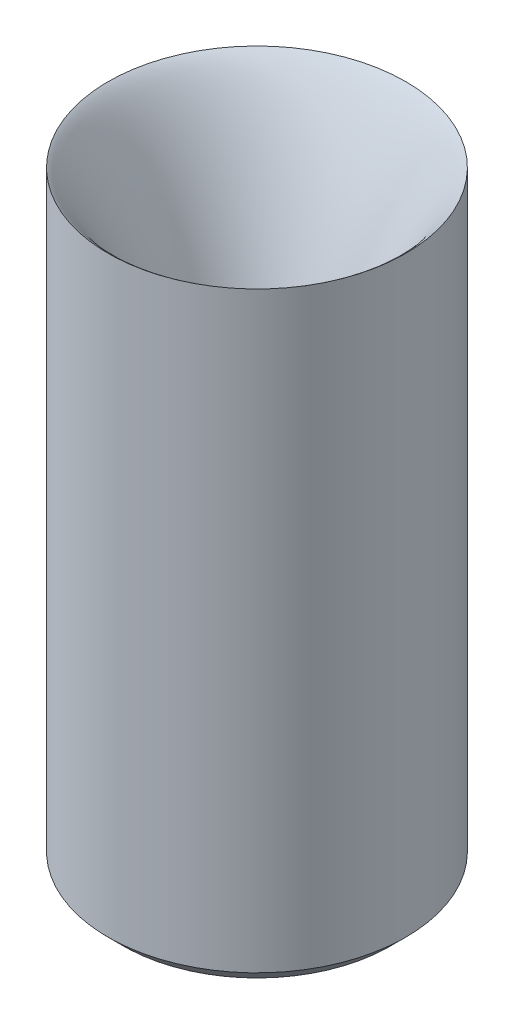
from build123d import *

# Parameters (mm, degrees)
CHAMFER_1_SIZE = 1


with BuildPart() as part:
    # Эскиз1 → Повернуть1 (revolve)
    with BuildSketch(Plane.XY):
        with BuildLine():
            Line((1.5, 0), (9.8, 0))
            Line((9.8, 0), (9.8, 40))
            add(Edge.make_bspline(
                [(9.8, 40), (7.453858919, 38.434475284), (0.9, 22), (0.9, 11)],
                knots=[0, 0, 0, 0, 1, 1, 1, 1], degree=3))
            Line((0.9, 11), (0.9, 8))
            Line((0.9, 8), (1.5, 8))
            Line((1.5, 8), (1.5, 0))
        make_face()
    revolve(axis=Axis((0, 0, 0), (0, 1, 0)))

    # Фаска1
    chamfer_1_edges = [part.edges().sort_by_distance(p)[0] for p in [
        (-1.5, 0, 0),
        (-9.8, 0, 0),
    ]]
    chamfer(chamfer_1_edges, length=CHAMFER_1_SIZE)


solid = part.part
